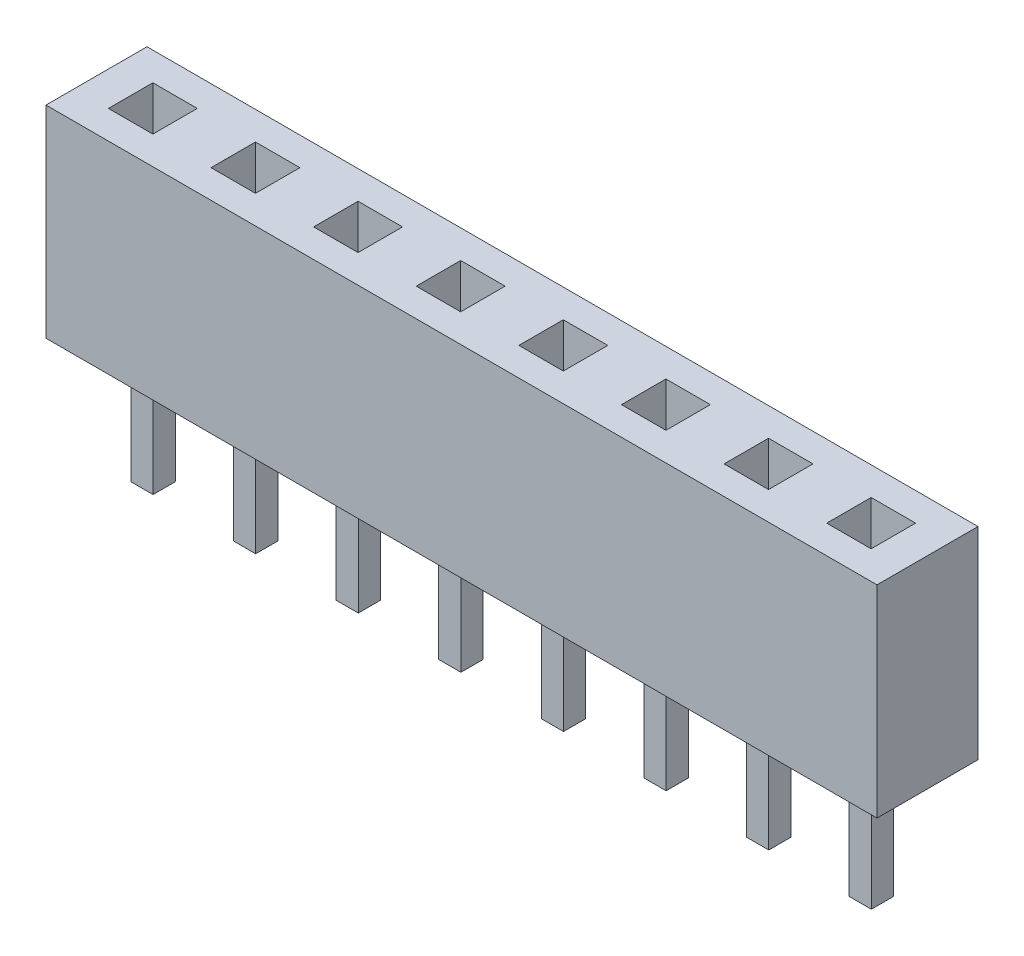
from build123d import *

# Parameters (mm, degrees)
SKETCH1_W             = 20.57
SKETCH1_H             = 5
BOSS_EXTRUDE1_DEPTH   = 1.25
SKETCH2_W             = 1.1
SKETCH2_H             = 1.1
CUT_EXTRUDE1_DEPTH    = 22.205834103
SKETCH3_W             = 20.57
SKETCH3_H             = 2.5
BOSS_EXTRUDE2_DEPTH   = 1
SKETCH4_W             = 0.55
SKETCH4_H             = 0.55
BOSS_EXTRUDE3_DEPTH   = 3
BOSS_EXTRUDE3_2_DEPTH = 3
BOSS_EXTRUDE3_3_DEPTH = 3
BOSS_EXTRUDE3_4_DEPTH = 3
BOSS_EXTRUDE3_5_DEPTH = 3
BOSS_EXTRUDE3_6_DEPTH = 3
BOSS_EXTRUDE3_7_DEPTH = 3
BOSS_EXTRUDE3_8_DEPTH = 3


with BuildPart() as part:
    # Sketch1 → Boss-Extrude1 (new, symmetric)
    with BuildSketch(Plane.XY):
        with Locations((10.285, 2.5)):
            Rectangle(SKETCH1_W, SKETCH1_H)
    extrude(amount=BOSS_EXTRUDE1_DEPTH, both=True)

    # Sketch2 → Cut-Extrude1 (cut, through all)
    with BuildSketch(Plane.XZ):
        with Locations((3.935, 0)):
            Rectangle(SKETCH2_W, SKETCH2_H)
        with Locations((1.395, 0)):
            Rectangle(SKETCH2_W, SKETCH2_H)
        with Locations((6.475, 0)):
            Rectangle(SKETCH2_W, SKETCH2_H)
        with Locations((9.015, 0)):
            Rectangle(SKETCH2_W, SKETCH2_H)
        with Locations((11.555, 0)):
            Rectangle(SKETCH2_W, SKETCH2_H)
        with Locations((14.095, 0)):
            Rectangle(SKETCH2_W, SKETCH2_H)
        with Locations((16.635, 0)):
            Rectangle(SKETCH2_W, SKETCH2_H)
        with Locations((19.175, 0)):
            Rectangle(SKETCH2_W, SKETCH2_H)
    extrude(amount=-CUT_EXTRUDE1_DEPTH, mode=Mode.SUBTRACT)

    # Sketch3 → Boss-Extrude2 (add)
    with BuildSketch(Plane.XZ):
        with Locations((10.285, 0)):
            Rectangle(SKETCH3_W, SKETCH3_H)
    extrude(amount=-BOSS_EXTRUDE2_DEPTH)


with BuildPart() as body_2:
    # Sketch4 → Boss-Extrude3 (new body)
    with BuildSketch(Plane.XZ):
        with Locations((1.4, 0)):
            Rectangle(SKETCH4_W, SKETCH4_H)
    extrude(amount=BOSS_EXTRUDE3_DEPTH)


with BuildPart() as body_3:
    # Sketch4 → Boss-Extrude3 2 (new body)
    with BuildSketch(Plane.XZ):
        with Locations((3.94, 0)):
            Rectangle(SKETCH4_W, SKETCH4_H)
    extrude(amount=BOSS_EXTRUDE3_2_DEPTH)


with BuildPart() as body_4:
    # Sketch4 → Boss-Extrude3 3 (new body)
    with BuildSketch(Plane.XZ):
        with Locations((6.48, 0)):
            Rectangle(SKETCH4_W, SKETCH4_H)
    extrude(amount=BOSS_EXTRUDE3_3_DEPTH)


with BuildPart() as body_5:
    # Sketch4 → Boss-Extrude3 4 (new body)
    with BuildSketch(Plane.XZ):
        with Locations((9.02, 0)):
            Rectangle(SKETCH4_W, SKETCH4_H)
    extrude(amount=BOSS_EXTRUDE3_4_DEPTH)


with BuildPart() as body_6:
    # Sketch4 → Boss-Extrude3 5 (new body)
    with BuildSketch(Plane.XZ):
        with Locations((11.56, 0)):
            Rectangle(SKETCH4_W, SKETCH4_H)
    extrude(amount=BOSS_EXTRUDE3_5_DEPTH)


with BuildPart() as body_7:
    # Sketch4 → Boss-Extrude3 6 (new body)
    with BuildSketch(Plane.XZ):
        with Locations((14.1, 0)):
            Rectangle(SKETCH4_W, SKETCH4_H)
    extrude(amount=BOSS_EXTRUDE3_6_DEPTH)


with BuildPart() as body_8:
    # Sketch4 → Boss-Extrude3 7 (new body)
    with BuildSketch(Plane.XZ):
        with Locations((16.64, 0)):
            Rectangle(SKETCH4_W, SKETCH4_H)
    extrude(amount=BOSS_EXTRUDE3_7_DEPTH)


with BuildPart() as body_9:
    # Sketch4 → Boss-Extrude3 8 (new body)
    with BuildSketch(Plane.XZ):
        with Locations((19.18, 0)):
            Rectangle(SKETCH4_W, SKETCH4_H)
    extrude(amount=BOSS_EXTRUDE3_8_DEPTH)


solid = Compound([part.part, body_2.part, body_3.part, body_4.part, body_5.part, body_6.part, body_7.part, body_8.part, body_9.part])
